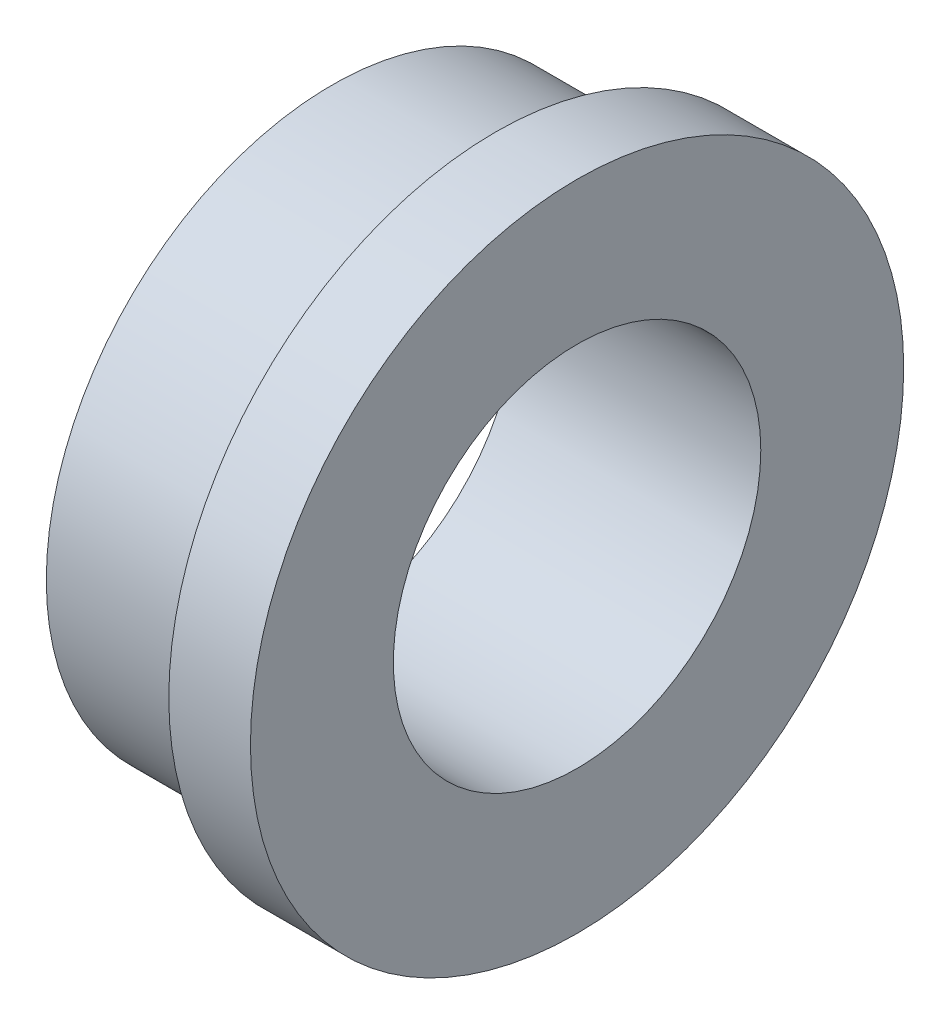
from build123d import *


with BuildPart() as part:
    # Sketch1 → Revolve1 (revolve)
    with BuildSketch(Plane.XY):
        Polygon((-19.05, 14.2875), (0, 14.2875), (0, 25.4), (-6.35, 25.4), (-6.35, 22.225), (-19.05, 22.225), align=None)
    revolve(axis=Axis((0, 0, 0), (-1, 0, 0)))


solid = part.part
